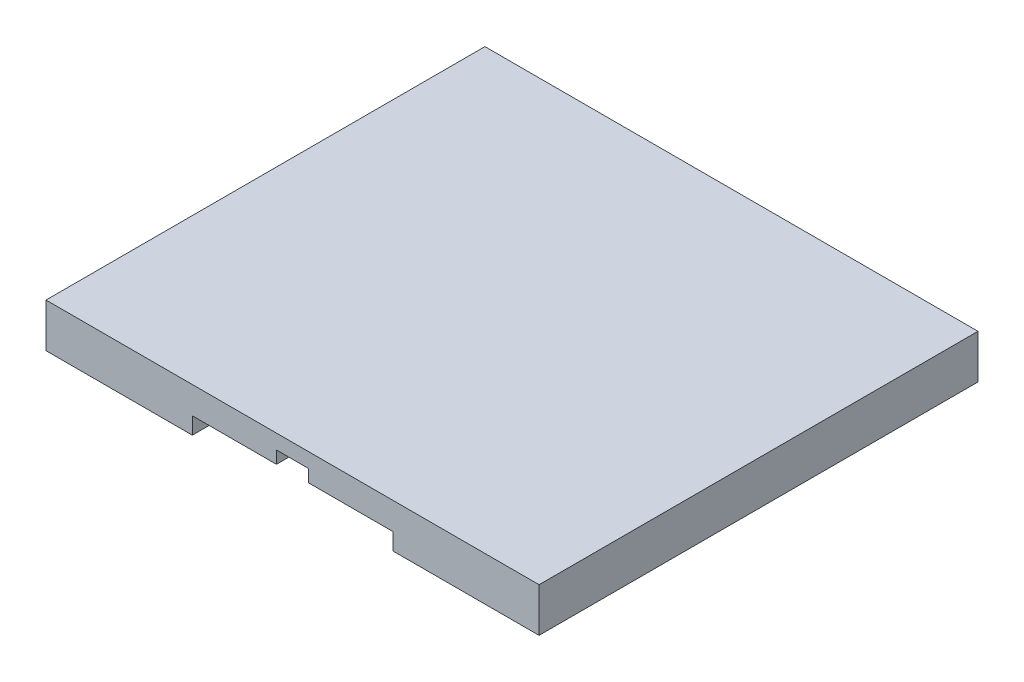
from build123d import *

# Parameters (mm, degrees)
BOSS_EXTRUDE3_DEPTH = 30
SKETCH8_W           = 137
SKETCH8_H           = 101
BOSS_EXTRUDE5_DEPTH = 10
SKETCH9_W           = 57.5
SKETCH9_H           = 101
BOSS_EXTRUDE6_DEPTH = 8.5
SKETCH10_W          = 57.5
SKETCH10_H          = 101
SKETCH10_W_2        = 58
BOSS_EXTRUDE7_DEPTH = 8.5
SKETCH13_R          = 2.5
CUT_EXTRUDE1_DEPTH  = 8
SKETCH14_R          = 2.5
CUT_EXTRUDE2_DEPTH  = 8
SKETCH15_R          = 2.5
CUT_EXTRUDE3_DEPTH  = 8
SKETCH16_R          = 2.5
CUT_EXTRUDE4_DEPTH  = 8


with BuildPart() as part:
    # Sketch5 → Boss-Extrude3 (new body)
    with BuildSketch(Plane(origin=(0, 0, 0), x_dir=(1, 0, 0), z_dir=(0, 1, 0))):
        Polygon((100, 199), (100, 300), (0, 300), (0, 0), (100, 0), (100, 101), (237, 101), (237, 0), (337, 0), (337, 300), (237, 300), (237, 199), align=None)
    extrude(amount=BOSS_EXTRUDE3_DEPTH)

    # Sketch8 → Boss-Extrude5 (add)
    with BuildSketch(Plane(origin=(0, 30, 0), x_dir=(1, 0, 0), z_dir=(0, 1, 0))):
        with Locations((168.5, 249.5)):
            Rectangle(SKETCH8_W, SKETCH8_H)
        with Locations((168.5, 50.5)):
            Rectangle(SKETCH8_W, SKETCH8_H)
    extrude(amount=-BOSS_EXTRUDE5_DEPTH)

    # Sketch9 → Boss-Extrude6 (add)
    with BuildSketch(Plane(origin=(0, 20, 0), x_dir=(1, 0, 0), z_dir=(0, 1, 0))):
        with Locations((128.75, 50.5)):
            Rectangle(SKETCH9_W, SKETCH9_H)
        with Locations((208.25, 50.5)):
            Rectangle(SKETCH9_W, SKETCH9_H)
    extrude(amount=-BOSS_EXTRUDE6_DEPTH)

    # Sketch10 → Boss-Extrude7 (add)
    with BuildSketch(Plane(origin=(0, 20, 0), x_dir=(1, 0, 0), z_dir=(0, 1, 0))):
        with Locations((128.75, 249.5)):
            Rectangle(SKETCH10_W, SKETCH10_H)
        with Locations((208, 249.5)):
            Rectangle(SKETCH10_W_2, SKETCH10_H)
    extrude(amount=-BOSS_EXTRUDE7_DEPTH)

    # Sketch13 → Cut-Extrude1 (cut)
    with BuildSketch(Plane.XZ.offset(-11.5)):
        with Locations((147.5, -8.5)):
            Circle(SKETCH13_R)
        with Locations((147.5, -92.5)):
            Circle(SKETCH13_R)
    extrude(amount=-CUT_EXTRUDE1_DEPTH, mode=Mode.SUBTRACT)

    # Sketch14 → Cut-Extrude2 (cut)
    with BuildSketch(Plane.XZ.offset(-11.5)):
        with Locations((189.5, -8.5)):
            Circle(SKETCH14_R)
        with Locations((189.5, -92.5)):
            Circle(SKETCH14_R)
    extrude(amount=-CUT_EXTRUDE2_DEPTH, mode=Mode.SUBTRACT)

    # Sketch15 → Cut-Extrude3 (cut)
    with BuildSketch(Plane.XZ.offset(-11.5)):
        with Locations((147.5, -207.5)):
            Circle(SKETCH15_R)
        with Locations((147.5, -291.5)):
            Circle(SKETCH15_R)
    extrude(amount=-CUT_EXTRUDE3_DEPTH, mode=Mode.SUBTRACT)

    # Sketch16 → Cut-Extrude4 (cut)
    with BuildSketch(Plane.XZ.offset(-11.5)):
        with Locations((189.5, -207.5)):
            Circle(SKETCH16_R)
        with Locations((189.5, -291.5)):
            Circle(SKETCH16_R)
    extrude(amount=-CUT_EXTRUDE4_DEPTH, mode=Mode.SUBTRACT)


solid = part.part
